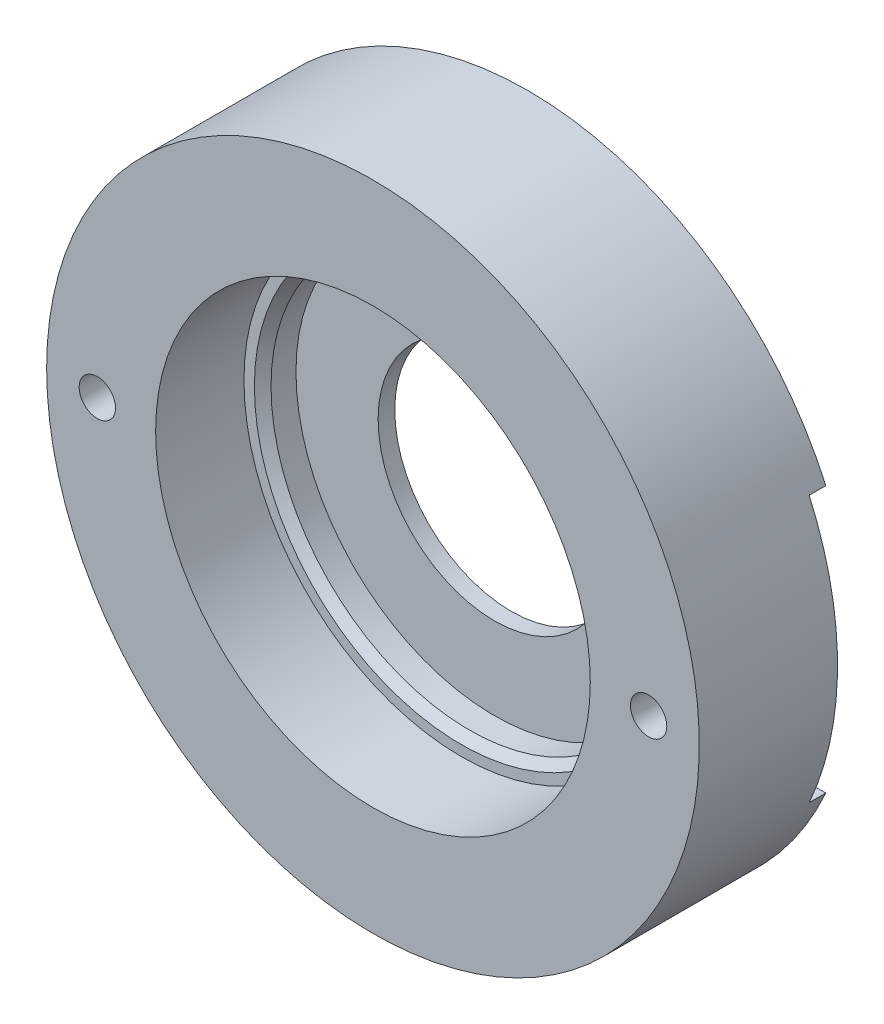
from build123d import *

# Parameters (mm, degrees)
SKETCH1_W          = 12.617819502
SKETCH1_H          = 2
SKETCH1_W_2        = 6.5532
SKETCH1_H_2        = 5.31
SKETCH2_R          = 1.0922
CUT_EXTRUDE1_DEPTH = 10.31
SKETCH3_W          = 45.123892984
SKETCH3_H          = 16
CUT_EXTRUDE2_DEPTH = 1
CHAMFER1_SIZE      = 0.5


with BuildPart() as part:
    # Sketch1 → Revolve1 (revolve)
    with BuildSketch(Plane(origin=(0, 0, 0), x_dir=(1, 0, 0), z_dir=(0, 1, 0))):
        with Locations((-13.308909751, 2.525473465)):
            Rectangle(SKETCH1_W, SKETCH1_H)
        Polygon((-11.938, 1.525473465), (-19.617819502, 1.525473465), (-19.617819502, -0.474526535), (-13.064619502, -0.474526535), (-11.938, -0.474526535), align=None)
        with Locations((-16.341219502, -3.129526535)):
            Rectangle(SKETCH1_W_2, SKETCH1_H_2)
    revolve(axis=Axis((0, 0, -25.411285606), (0, 0, 1)))

    # Sketch2 → Cut-Extrude1 (cut, through all)
    with BuildSketch(Plane(origin=(0, 0, -3.525473465), x_dir=(-1, 0, 0), z_dir=(0, 0, -1))):
        with Locations((16.57, 0)):
            Circle(SKETCH2_R)
        with Locations((-16.57, 0)):
            Circle(SKETCH2_R)
    extrude(amount=-CUT_EXTRUDE1_DEPTH, mode=Mode.SUBTRACT)

    # Sketch3 → Cut-Extrude2 (cut)
    with BuildSketch(Plane(origin=(0, 0, -3.525473465), x_dir=(-1, 0, 0), z_dir=(0, 0, -1))):
        Rectangle(SKETCH3_W, SKETCH3_H)
    extrude(amount=-CUT_EXTRUDE2_DEPTH, mode=Mode.SUBTRACT)

    # Chamfer1
    chamfer1_edges = [part.edges().sort_by_distance(p)[0] for p in [
        (11.938, 0, 0.474526535),
    ]]
    chamfer(chamfer1_edges, length=CHAMFER1_SIZE)


solid = part.part
